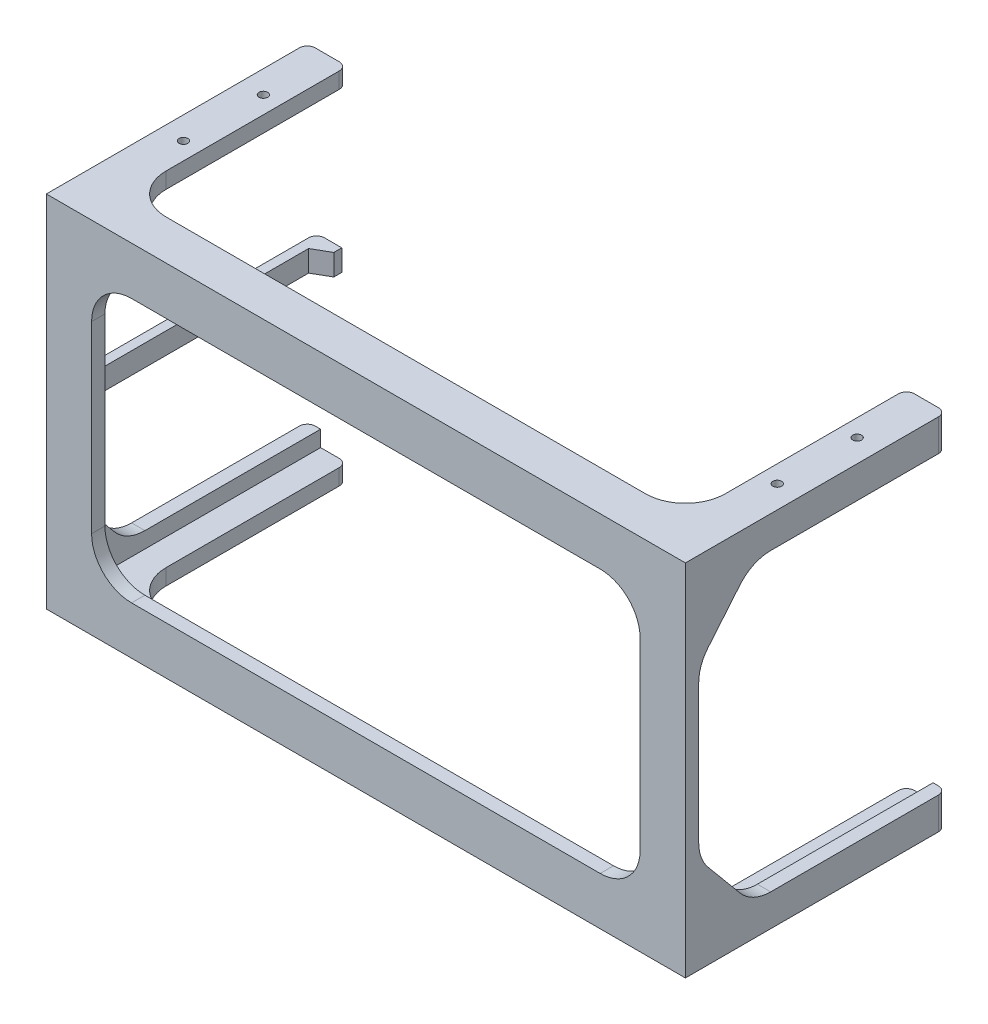
from build123d import *

# Parameters (mm, degrees)
SKETCH1_W                                     = 230
SKETCH1_H                                     = 123
SKETCH1_W_2                                   = 206
SKETCH1_H_2                                   = 99
BOSS_EXTRUDE1_DEPTH                           = 5
SKETCH2_W                                     = 230
SKETCH2_H                                     = 5
BOSS_EXTRUDE2_DEPTH                           = 6
BOSS_EXTRUDE3_DEPTH                           = 5
FILLET1_R                                     = 15
BOSS_EXTRUDE4_DEPTH                           = 4
FILLET2_R                                     = 5
FILLET3_R                                     = 3
CSK_FOR_4_FLAT_HEAD_MACHINE_SCREW1_AT_2_COUNT = 2
CSK_FOR_4_FLAT_HEAD_MACHINE_SCREW1_AT_2_PITCH = 30
CSK_FOR_4_FLAT_HEAD_MACHINE_SCREW1_AT_3_COUNT = 2
CSK_FOR_4_FLAT_HEAD_MACHINE_SCREW1_AT_3_PITCH = 225.008888713
CSK_FOR_4_FLAT_HEAD_MACHINE_SCREW1_AT_4_COUNT = 2
CSK_FOR_4_FLAT_HEAD_MACHINE_SCREW1_AT_4_PITCH = 223


with BuildPart() as part:
    # Sketch1 → Boss-Extrude1 (new body)
    with BuildSketch(Plane.XY):
        Rectangle(SKETCH1_W, SKETCH1_H)
        Rectangle(SKETCH1_W_2, SKETCH1_H_2, mode=Mode.SUBTRACT)
    extrude(amount=BOSS_EXTRUDE1_DEPTH)

    # Sketch2 → Boss-Extrude2 (add)
    with BuildSketch(Plane(origin=(0, 61.5, 0), x_dir=(1, 0, 0), z_dir=(0, 1, 0))):
        Polygon((-115, 10), (-115, 0), (115, 0), (115, 10), (115, 93), (105, 93), (105, 10), (-105, 10), (-105, 93), (-115, 93), align=None)
        with Locations((0, -2.5)):
            Rectangle(SKETCH2_W, SKETCH2_H)
    boss_extrude2 = extrude(amount=BOSS_EXTRUDE2_DEPTH)

    # Mirror1: Boss-Extrude2 across plane
    add(boss_extrude2.mirror(Plane.ZX))

    # Sketch3 → Boss-Extrude3 (add)
    with BuildSketch(Plane.ZY.offset(115)):
        Polygon((-93, 61.5), (0, 61.5), (0, -61.5), (-93, -61.5), (-93, -67.5), (5, -67.5), (5, 67.5), (-93, 67.5), align=None)
        Polygon((0, 61.5), (-25, 61.5), (-20, 55.5), (0, 31.5), align=None)
        Polygon((0, -61.5), (0, -31.5), (-20, -55.5), (-25, -61.5), align=None)
        Polygon((-20, 55.5), (-25, 61.5), (-93, 61.5), (-93, 55.5), align=None)
        Polygon((-25, -61.5), (-20, -55.5), (-93, -55.5), (-93, -61.5), align=None)
    boss_extrude3 = extrude(amount=BOSS_EXTRUDE3_DEPTH)

    # Mirror2: Boss-Extrude3 across plane
    add(boss_extrude3.mirror(Plane(origin=(0, 0, 0), x_dir=(0, 0, 1), z_dir=(1, 0, 0))))

    # Fillet1
    fillet1_edges = [part.edges().sort_by_distance(p)[0] for p in [
        (117.5, 55.5, -20),
        (117.5, -55.5, -20),
        (117.5, -31.5, 0),
        (117.5, 31.5, 0),
        (-103, -49.5, 2.5),
        (103, -49.5, 2.5),
        (103, 49.5, 2.5),
        (-103, 49.5, 2.5),
        (105, 64.5, -10),
        (-105, 64.5, -10),
        (-105, -64.5, -10),
        (105, -64.5, -10),
        (-117.5, 55.5, -20),
        (-117.5, 31.5, 0),
        (-117.5, -31.5, 0),
        (-117.5, -55.5, -20),
    ]]
    fillet(fillet1_edges, radius=FILLET1_R)

    # Sketch4 → Boss-Extrude4 (add, symmetric)
    with BuildSketch(Plane(origin=(0, 0, 0), x_dir=(1, 0, 0), z_dir=(0, 1, 0))):
        Polygon((-120, 96.464101615), (-120, 0), (-116.5, 0), (-116.5, 90), (-110.5, 93.464101615), (-110.5, 96.464101615), align=None)
    extrude(amount=BOSS_EXTRUDE4_DEPTH, both=True)

    # Fillet2
    fillet2_edges = [part.edges().sort_by_distance(p)[0] for p in [
        (-118.25, 4, 0),
        (-118.25, -4, 0),
    ]]
    fillet(fillet2_edges, radius=FILLET2_R)

    # Fillet3
    fillet3_edges = [part.edges().sort_by_distance(p)[0] for p in [
        (120, 61.5, -93),
        (120, -61.5, -93),
        (105, 64.5, -93),
        (-120, 0, -96.464101615),
        (-105, 64.5, -93),
        (-105, -64.5, -93),
        (105, -64.5, -93),
        (-120, -61.5, -93),
        (-120, 61.5, -93),
    ]]
    fillet(fillet3_edges, radius=FILLET3_R)

    # Sketch6 → CSK for #4 Flat Head Machine Screw1 (revolve, cut)
    with BuildSketch(Plane(origin=(111.5, 61.5, -68), x_dir=(0, 0, -1), z_dir=(1, 0, 0))):
        Polygon((0, 0), (0, 6), (1.63195, 6), (1.63195, 2.409835609), (2.857501397, 1), (2.857501397, 0), align=None)
    csk_for_4_flat_head_machine_screw1 = revolve(axis=Axis((111.5, 55.15, -68), (0, 1, 0)), mode=Mode.SUBTRACT)

    # CSK for #4 Flat Head Machine Screw1 at 2: CSK for #4 Flat Head Machine Screw1 ×2
    with Locations(*[(0, 0, i * CSK_FOR_4_FLAT_HEAD_MACHINE_SCREW1_AT_2_PITCH) for i in range(1, CSK_FOR_4_FLAT_HEAD_MACHINE_SCREW1_AT_2_COUNT)]):
        add(csk_for_4_flat_head_machine_screw1, mode=Mode.SUBTRACT)

    # CSK for #4 Flat Head Machine Screw1 at 3: CSK for #4 Flat Head Machine Screw1 ×2
    with Locations(*[Vector(-0.991071958, 0, 0.133328066) * (i * CSK_FOR_4_FLAT_HEAD_MACHINE_SCREW1_AT_3_PITCH) for i in range(1, CSK_FOR_4_FLAT_HEAD_MACHINE_SCREW1_AT_3_COUNT)]):
        add(csk_for_4_flat_head_machine_screw1, mode=Mode.SUBTRACT)

    # CSK for #4 Flat Head Machine Screw1 at 4: CSK for #4 Flat Head Machine Screw1 ×2
    with Locations(*[(-i * CSK_FOR_4_FLAT_HEAD_MACHINE_SCREW1_AT_4_PITCH, 0, 0) for i in range(1, CSK_FOR_4_FLAT_HEAD_MACHINE_SCREW1_AT_4_COUNT)]):
        add(csk_for_4_flat_head_machine_screw1, mode=Mode.SUBTRACT)


solid = part.part
